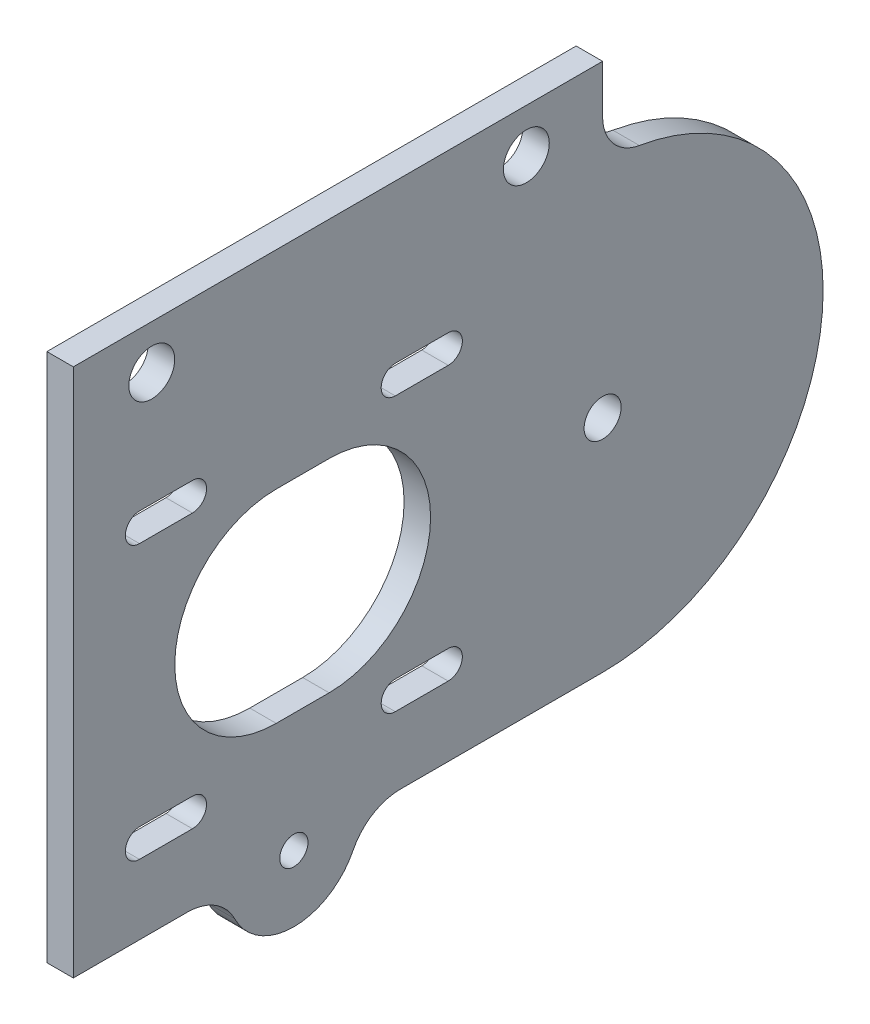
from build123d import *

# Parameters (mm, degrees)
SKETCH1_R           = 2.1
BOSS_EXTRUDE2_DEPTH = 3
SKETCH2_R           = 7.5
BOSS_EXTRUDE3_DEPTH = 3
SKETCH3_W           = 60
SKETCH3_H           = 10
SKETCH3_R           = 2.6
BOSS_EXTRUDE4_DEPTH = 3
FILLET3_R           = 5
SKETCH4_R           = 1.6
CUT_EXTRUDE1_DEPTH  = 4
FILLET4_R           = 6


with BuildPart() as part:
    # Sketch1 → Boss-Extrude2 (new body)
    with BuildSketch(Plane(origin=(0, 0, 0), x_dir=(0, 0, -1), z_dir=(1, 0, 0))):
        with BuildLine():
            ThreePointArc((35, -25), (60, 0), (35, 25))
            Line((35, 25), (-25, 25))
            Line((-25, 25), (-25, -25))
            Line((-25, -25), (35, -25))
        make_face()
        with BuildLine():
            Line((-11.5, -17.1), (-17.5, -17.1))
            ThreePointArc((-17.5, -17.1), (-19.1, -15.5), (-17.5, -13.9))
            Line((-17.5, -13.9), (-11.5, -13.9))
            ThreePointArc((-11.5, -13.9), (-9.9, -15.5), (-11.5, -17.1))
        make_face(mode=Mode.SUBTRACT)
        with Locations((35, 0)):
            Circle(SKETCH1_R, mode=Mode.SUBTRACT)
        with BuildLine():
            Line((11.5, 17.1), (17.5, 17.1))
            ThreePointArc((17.5, 17.1), (19.1, 15.5), (17.5, 13.9))
            Line((17.5, 13.9), (11.5, 13.9))
            ThreePointArc((11.5, 13.9), (9.9, 15.5), (11.5, 17.1))
        make_face(mode=Mode.SUBTRACT)
        with BuildLine():
            ThreePointArc((4, 11.5), (15.5, 0), (4, -11.5))
            Line((4, -11.5), (-2, -11.5))
            ThreePointArc((-2, -11.5), (-13.5, 0), (-2, 11.5))
            Line((-2, 11.5), (4, 11.5))
        make_face(mode=Mode.SUBTRACT)
        with BuildLine():
            Line((11.5, -13.9), (17.5, -13.9))
            ThreePointArc((17.5, -13.9), (19.1, -15.5), (17.5, -17.1))
            Line((17.5, -17.1), (11.5, -17.1))
            ThreePointArc((11.5, -17.1), (9.9, -15.5), (11.5, -13.9))
        make_face(mode=Mode.SUBTRACT)
        with BuildLine():
            ThreePointArc((-17.5, 13.9), (-19.1, 15.5), (-17.5, 17.1))
            Line((-17.5, 17.1), (-11.5, 17.1))
            ThreePointArc((-11.5, 17.1), (-9.9, 15.5), (-11.5, 13.9))
            Line((-11.5, 13.9), (-17.5, 13.9))
        make_face(mode=Mode.SUBTRACT)
    extrude(amount=BOSS_EXTRUDE2_DEPTH)

    # Sketch2 → Boss-Extrude3 (add)
    with BuildSketch(Plane(origin=(3, 0, 0), x_dir=(0, 0, -1), z_dir=(1, 0, 0))):
        with Locations((0, -24.979991994)):
            Circle(SKETCH2_R)
    extrude(amount=-BOSS_EXTRUDE3_DEPTH)

    # Sketch3 → Boss-Extrude4 (add)
    with BuildSketch(Plane(origin=(3, 0, 0), x_dir=(0, 0, -1), z_dir=(1, 0, 0))):
        with Locations((5, 30)):
            Rectangle(SKETCH3_W, SKETCH3_H)
        with Locations((-16.105832267, 30)):
            Circle(SKETCH3_R, mode=Mode.SUBTRACT)
        with Locations((26.356099555, 30)):
            Circle(SKETCH3_R, mode=Mode.SUBTRACT)
    extrude(amount=-BOSS_EXTRUDE4_DEPTH)

    # Fillet3
    fillet3_edges = [part.edges().sort_by_distance(p)[0] for p in [
        (1.5, 25, -35),
    ]]
    fillet(fillet3_edges, radius=FILLET3_R)

    # Sketch4 → Cut-Extrude1 (cut, through all)
    with BuildSketch(Plane.ZY):
        with Locations((0, -24.979991994)):
            Circle(SKETCH4_R)
    extrude(amount=-CUT_EXTRUDE1_DEPTH, mode=Mode.SUBTRACT)

    # Fillet4
    fillet4_edges = [part.edges().sort_by_distance(p)[0] for p in [
        (1.5, -25, 7.499973312),
        (1.5, -25, -7.499973312),
    ]]
    fillet(fillet4_edges, radius=FILLET4_R)


solid = part.part
